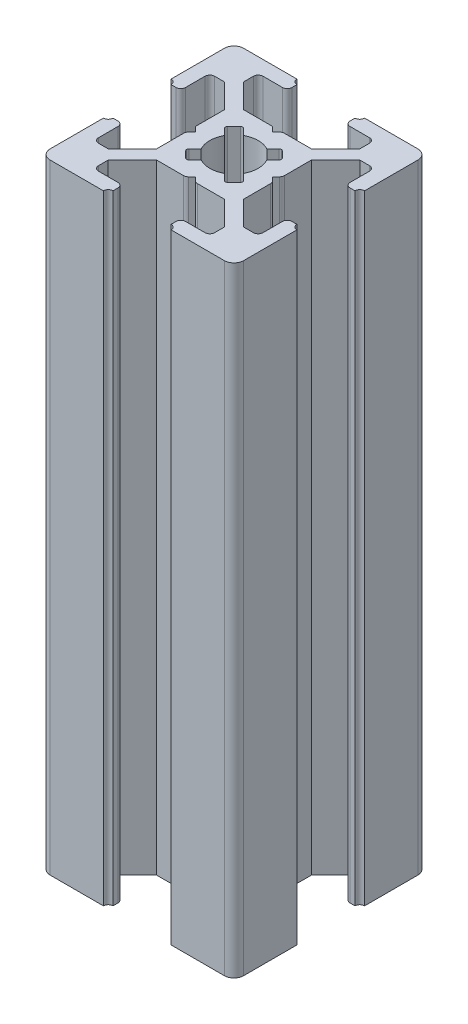
from build123d import *

# Parameters (mm, degrees)
BOSS_EXTRUDE1_DEPTH = 64
FILLET1_R           = 1
CUT_EXTRUDE1_DEPTH  = 65
FILLET2_R           = 0.5
FILLET3_R           = 0.25


with BuildPart() as part:
    # Sketch3 → Boss-Extrude1 (new body)
    with BuildSketch(Plane(origin=(0, 0, 0), x_dir=(1, 0, 0), z_dir=(0, 1, 0))):
        with BuildLine():
            Line((7, 18.5), (7, 19.5))
            ThreePointArc((7, 19.5), (6.646446609, 19.646446609), (6.5, 20))
            Line((6.5, 20), (0, 20))
            Line((0, 20), (0, 13.5))
            ThreePointArc((0, 13.5), (0.353553391, 13.353553391), (0.5, 13))
            Line((0.5, 13), (1.5, 13))
            Line((1.5, 13), (1.5, 16))
            Line((1.5, 16), (3, 16))
            Line((3, 16), (5.5, 13.5))
            Line((5.5, 13.5), (5.5, 10.5))
            Line((5.5, 10.5), (6, 10))
            Line((6, 10), (5.5, 9.5))
            Line((5.5, 9.5), (5.5, 6.5))
            Line((5.5, 6.5), (3, 4))
            Line((3, 4), (1.5, 4))
            Line((1.5, 4), (1.5, 7))
            Line((1.5, 7), (0.5, 7))
            ThreePointArc((0.5, 7), (0.353553391, 6.646446609), (0, 6.5))
            Line((0, 6.5), (0, 0))
            Line((0, 0), (6.5, 0))
            ThreePointArc((6.5, 0), (6.646446609, 0.353553391), (7, 0.5))
            Line((7, 0.5), (7, 1.5))
            Line((7, 1.5), (4, 1.5))
            Line((4, 1.5), (4, 3))
            Line((4, 3), (6.5, 5.5))
            Line((6.5, 5.5), (9.5, 5.5))
            Line((9.5, 5.5), (10, 6))
            Line((10, 6), (10.5, 5.5))
            Line((10.5, 5.5), (13.5, 5.5))
            Line((13.5, 5.5), (16, 3))
            Line((16, 3), (16, 1.5))
            Line((16, 1.5), (13, 1.5))
            Line((13, 1.5), (13, 0.5))
            ThreePointArc((13, 0.5), (13.353553391, 0.353553391), (13.5, 0))
            Line((13.5, 0), (20, 0))
            Line((20, 0), (20, 6.5))
            ThreePointArc((20, 6.5), (19.646446609, 6.646446609), (19.5, 7))
            Line((19.5, 7), (18.5, 7))
            Line((18.5, 7), (18.5, 4))
            Line((18.5, 4), (17, 4))
            Line((17, 4), (14.5, 6.5))
            Line((14.5, 6.5), (14.5, 9.5))
            Line((14.5, 9.5), (14, 10))
            Line((14, 10), (14.5, 10.5))
            Line((14.5, 10.5), (14.5, 13.5))
            Line((14.5, 13.5), (17, 16))
            Line((17, 16), (18.5, 16))
            Line((18.5, 16), (18.5, 13))
            Line((18.5, 13), (19.5, 13))
            ThreePointArc((19.5, 13), (19.646446609, 13.353553391), (20, 13.5))
            Line((20, 13.5), (20, 20))
            Line((20, 20), (13.5, 20))
            ThreePointArc((13.5, 20), (13.353553391, 19.646446609), (13, 19.5))
            Line((13, 19.5), (13, 18.5))
            Line((13, 18.5), (16, 18.5))
            Line((16, 18.5), (16, 17))
            Line((16, 17), (13.5, 14.5))
            Line((13.5, 14.5), (10.5, 14.5))
            Line((10.5, 14.5), (10, 14))
            Line((10, 14), (9.5, 14.5))
            Line((9.5, 14.5), (6.5, 14.5))
            Line((6.5, 14.5), (4, 17))
            Line((4, 17), (4, 18.5))
            Line((4, 18.5), (7, 18.5))
        make_face()
    extrude(amount=BOSS_EXTRUDE1_DEPTH)

    # Fillet1
    fillet1_edges = [part.edges().sort_by_distance(p)[0] for p in [
        (20, 32, 0),
        (0, 32, 0),
        (0, 32, -20),
        (20, 32, -20),
    ]]
    fillet(fillet1_edges, radius=FILLET1_R)

    # Sketch4 → Cut-Extrude1 (cut, through all)
    with BuildSketch(Plane(origin=(0, 64, 0), x_dir=(1, 0, 0), z_dir=(0, 1, 0))):
        with BuildLine():
            Line((10, 11), (11.195582496, 12.195582496))
            ThreePointArc((11.195582496, 12.195582496), (10, 12.5), (8.804417504, 12.195582496))
            Line((8.804417504, 12.195582496), (10, 11))
        make_face()
        with BuildLine():
            ThreePointArc((12.195582496, 11.195582496), (11.767766953, 11.767766953), (11.195582496, 12.195582496))
            Line((11.195582496, 12.195582496), (10, 11))
            Line((10, 11), (11, 10))
            Line((11, 10), (12.195582496, 11.195582496))
        make_face()
        with BuildLine():
            Line((9, 10), (10, 11))
            Line((10, 11), (8.804417504, 12.195582496))
            ThreePointArc((8.804417504, 12.195582496), (8.232233047, 11.767766953), (7.804417504, 11.195582496))
            Line((7.804417504, 11.195582496), (9, 10))
        make_face()
        Polygon((11, 10), (10, 11), (9, 10), (10, 9), align=None)
        with BuildLine():
            Line((7.804417504, 8.804417504), (9, 10))
            Line((9, 10), (7.804417504, 11.195582496))
            ThreePointArc((7.804417504, 11.195582496), (7.5, 10), (7.804417504, 8.804417504))
        make_face()
        with BuildLine():
            Line((10, 9), (9, 10))
            Line((9, 10), (7.804417504, 8.804417504))
            ThreePointArc((7.804417504, 8.804417504), (8.232233047, 8.232233047), (8.804417504, 7.804417504))
            Line((8.804417504, 7.804417504), (10, 9))
        make_face()
        with BuildLine():
            Line((11.195582496, 7.804417504), (10, 9))
            Line((10, 9), (8.804417504, 7.804417504))
            ThreePointArc((8.804417504, 7.804417504), (10, 7.5), (11.195582496, 7.804417504))
        make_face()
        with BuildLine():
            Line((12.195582496, 8.804417504), (11, 10))
            Line((11, 10), (10, 9))
            Line((10, 9), (11.195582496, 7.804417504))
            ThreePointArc((11.195582496, 7.804417504), (11.767766953, 8.232233047), (12.195582496, 8.804417504))
        make_face()
        with BuildLine():
            ThreePointArc((12.5, 10), (12.422700584, 10.616864556), (12.195582496, 11.195582496))
            Line((12.195582496, 11.195582496), (11, 10))
            Line((11, 10), (12.195582496, 8.804417504))
            ThreePointArc((12.195582496, 8.804417504), (12.422700584, 9.383135444), (12.5, 10))
        make_face()
        with BuildLine():
            ThreePointArc((8.804417504, 7.804417504), (8.232233047, 8.232233047), (7.804417504, 8.804417504))
            Line((7.804417504, 8.804417504), (7, 8))
            Line((7, 8), (8, 7))
            Line((8, 7), (8.804417504, 7.804417504))
        make_face()
        with BuildLine():
            Line((13, 8), (12.195582496, 8.804417504))
            ThreePointArc((12.195582496, 8.804417504), (11.767766953, 8.232233047), (11.195582496, 7.804417504))
            Line((11.195582496, 7.804417504), (12, 7))
            Line((12, 7), (13, 8))
        make_face()
        with BuildLine():
            Line((13, 12), (12, 13))
            Line((12, 13), (11.195582496, 12.195582496))
            ThreePointArc((11.195582496, 12.195582496), (11.767766953, 11.767766953), (12.195582496, 11.195582496))
            Line((12.195582496, 11.195582496), (13, 12))
        make_face()
        with BuildLine():
            ThreePointArc((7.804417504, 11.195582496), (8.232233047, 11.767766953), (8.804417504, 12.195582496))
            Line((8.804417504, 12.195582496), (8, 13))
            Line((8, 13), (7, 12))
            Line((7, 12), (7.804417504, 11.195582496))
        make_face()
    extrude(amount=-CUT_EXTRUDE1_DEPTH, mode=Mode.SUBTRACT)

    # Fillet2
    fillet2_edges = [part.edges().sort_by_distance(p)[0] for p in [
        (18.5, 32, -13),
        (18.5, 32, -16),
        (14.5, 32, -10.5),
        (14.5, 32, -9.5),
        (18.5, 32, -4),
        (18.5, 32, -7),
        (13, 32, -1.5),
        (16, 32, -1.5),
        (10.5, 32, -5.5),
        (9.5, 32, -5.5),
        (4, 32, -1.5),
        (7, 32, -1.5),
        (1.5, 32, -7),
        (1.5, 32, -4),
        (5.5, 32, -9.5),
        (5.5, 32, -10.5),
        (1.5, 32, -16),
        (1.5, 32, -13),
        (7, 32, -18.5),
        (4, 32, -18.5),
        (9.5, 32, -14.5),
        (10.5, 32, -14.5),
        (16, 32, -18.5),
        (13, 32, -18.5),
    ]]
    fillet(fillet2_edges, radius=FILLET2_R)

    # Fillet3
    fillet3_edges = [part.edges().sort_by_distance(p)[0] for p in [
        (7, 32, -12),
        (8, 32, -13),
        (12, 32, -13),
        (13, 32, -12),
        (13, 32, -8),
        (12, 32, -7),
        (8, 32, -7),
        (7, 32, -8),
    ]]
    fillet(fillet3_edges, radius=FILLET3_R)


solid = part.part
